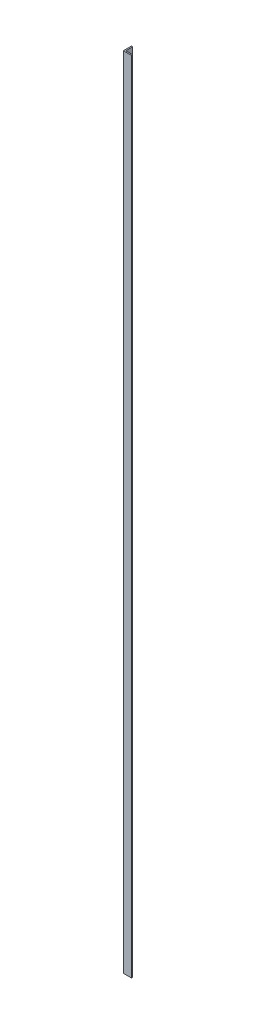
from build123d import *

# Parameters (mm, degrees)
BOSS_EXTRUDE1_DEPTH = 4978.4


with BuildPart() as part:
    # Sketch1 → Boss-Extrude1 (new body)
    with BuildSketch(Plane(origin=(0, 0, 0), x_dir=(1, 0, 0), z_dir=(0, 1, 0))):
        Polygon((0, 0), (0, 50.8), (7.62, 50.8), (7.62, 7.62), (50.8, 7.62), (50.8, 0), align=None)
    extrude(amount=BOSS_EXTRUDE1_DEPTH)


solid = part.part
